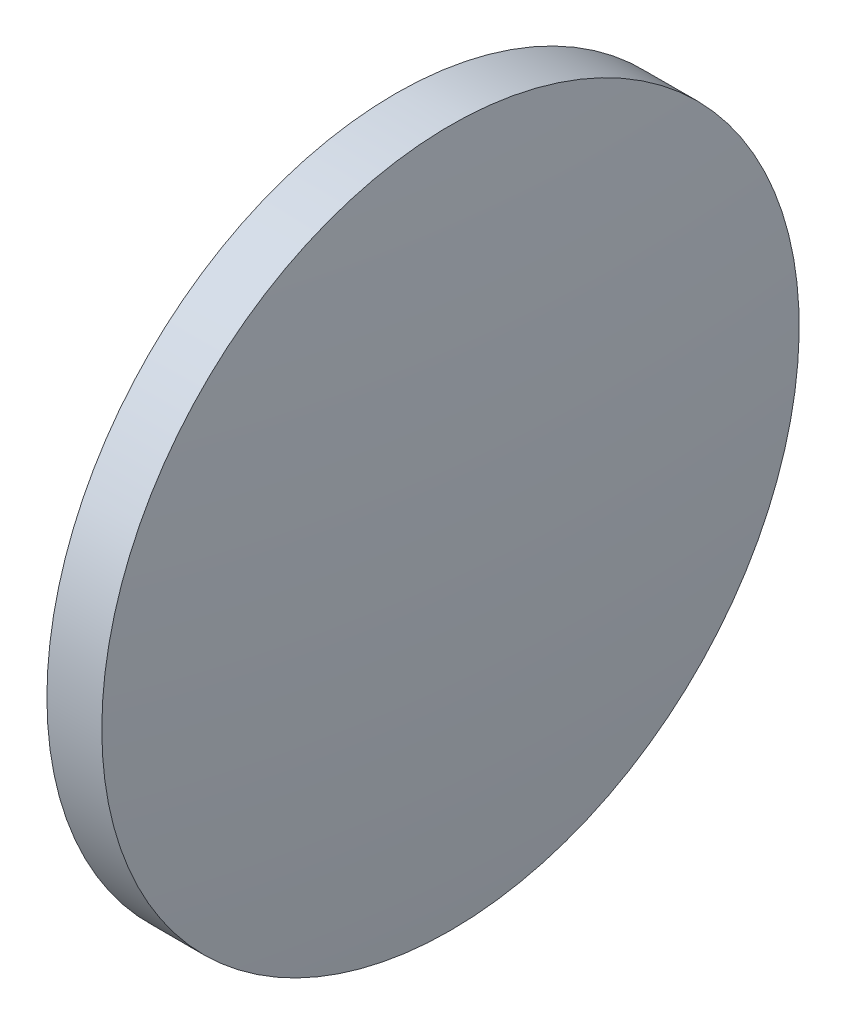
from build123d import *

# Parameters (mm, degrees)
SKETCH_1_ONE_SIDE_W = 1.999342857
SKETCH_1_ONE_SIDE_H = 12.7


with BuildPart() as part:
    # 草图1 one side → 旋转1 (revolve)
    with BuildSketch(Plane.XY, mode=Mode.PRIVATE) as revolve_1_sk:
        with Locations((86.458193775, 54.966113023)):
            Rectangle(SKETCH_1_ONE_SIDE_W, SKETCH_1_ONE_SIDE_H)
        with BuildLine():
            Line((84.858356632, 48.616113023), (85.458522346, 48.616113023))
            Line((85.458522346, 48.616113023), (85.458522346, 61.316113023))
            ThreePointArc((85.458522346, 61.316113023), (85.008481737, 54.973199598), (84.858356632, 48.616113023))
        make_face()
        with BuildLine():
            Line((87.457865203, 48.616113023), (88.058030918, 48.616113023))
            ThreePointArc((88.058030918, 48.616113023), (87.907905813, 54.973199598), (87.457865203, 61.316113023))
            Line((87.457865203, 61.316113023), (87.457865203, 48.616113023))
        make_face()
    revolve(revolve_1_sk.sketch.rotate(Axis((79.305401351, 48.616113023, 0), (1, 0, 0)), 90), axis=Axis((79.305401351, 48.616113023, 0), (1, 0, 0)))  # turned: the seam where the file's is


solid = part.part
